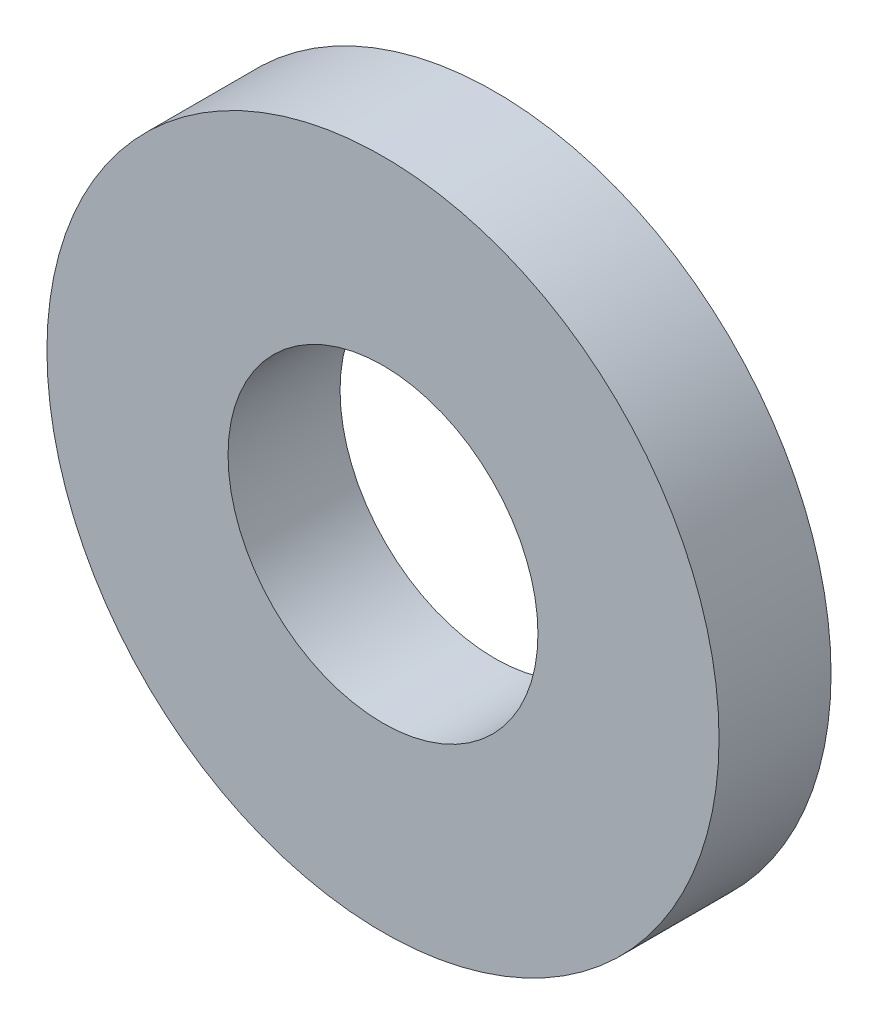
from build123d import *

# Parameters (mm, degrees)
SKETCH_1_R          = 9
EXTRUDE_1_DEPTH     = 3
SKETCH_2_R          = 4.15
CUT_EXTRUDE_1_DEPTH = 4


with BuildPart() as part:
    # 草图1 → 凸台-拉伸1 (new body)
    with BuildSketch(Plane.XY):
        Circle(SKETCH_1_R)
    extrude(amount=EXTRUDE_1_DEPTH)

    # 草图2 → 切除-拉伸1 (cut, through all)
    with BuildSketch(Plane.XY.offset(3)):
        Circle(SKETCH_2_R)
    extrude(amount=-CUT_EXTRUDE_1_DEPTH, mode=Mode.SUBTRACT)


solid = part.part
